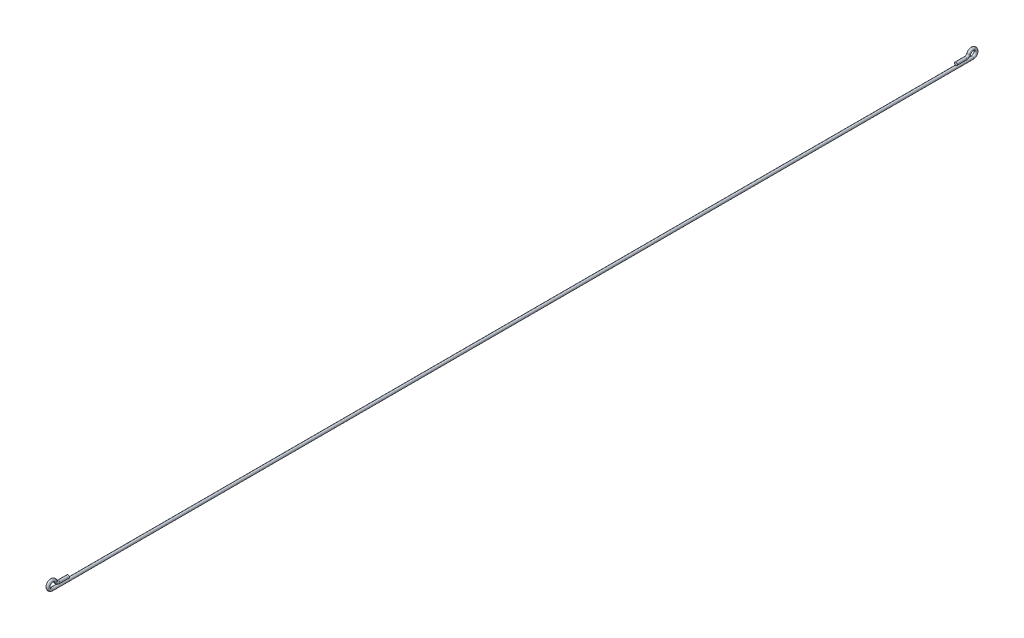
from build123d import *

# Parameters (mm, degrees)
SKETCH1_R = 1.5


with BuildPart() as part:
    # Sweep1: sweep along a path in Sketch2
    with BuildLine(Plane(origin=(0, 0, 0), x_dir=(0, 0, -1), z_dir=(1, 0, 0))) as sweep1_path:
        Line((472.583801513, -3), (-17.416198487, -3))
        ThreePointArc((-17.416198487, -3), (-20.732823277, 3.236067977), (-13.708099244, 2.5))
        ThreePointArc((-13.708099244, 2.5), (-12.236067977, 0.68337521), (-10, 0))
        Line((-10, 0), (0, 0))
    # Sketch1 → Sweep1 (sweep)
    with BuildSketch(Plane.XY):
        Circle(SKETCH1_R)
    sweep1 = sweep(path=sweep1_path.line)

    # Mirror1: Sweep1 across plane
    add(sweep1.mirror(Plane(origin=(0, -3, -472.583801513), x_dir=(1, 0, 0), z_dir=(0, 0, -1))))


solid = part.part
